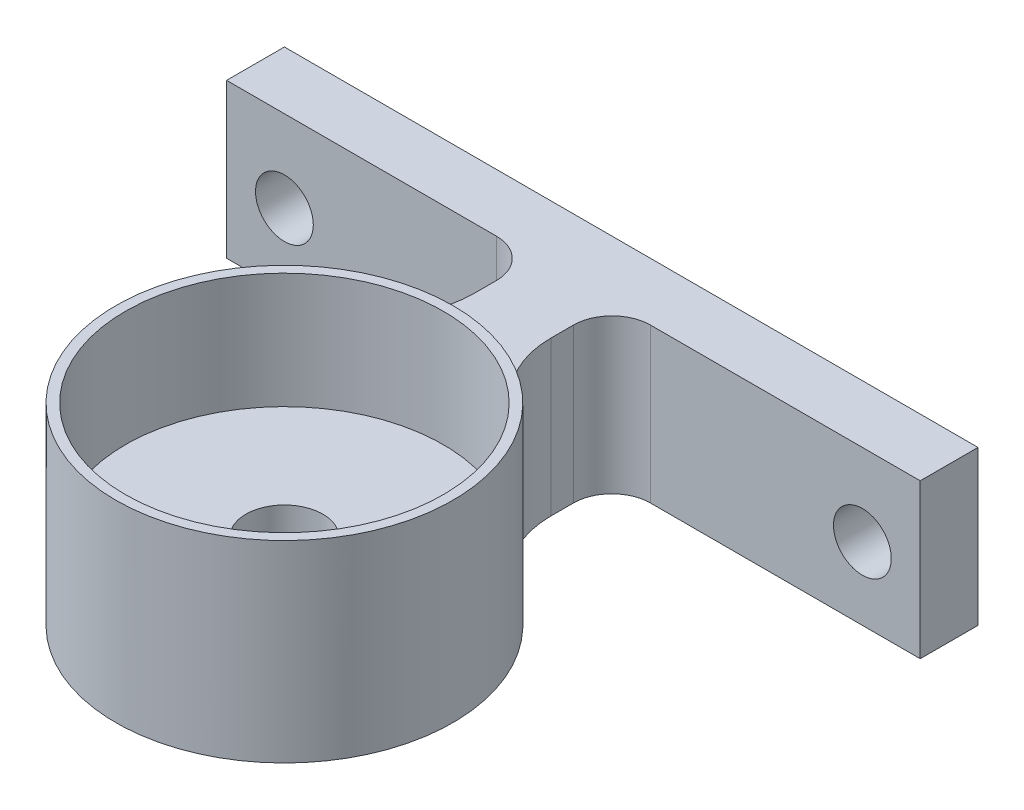
from build123d import *

# Parameters (mm, degrees)
SKETCH_1_R          = 8.75
SKETCH_1_R_2        = 8.25
EXTRUDE_2_DEPTH     = 10
SKETCH_2_R          = 8.25
SKETCH_2_R_2        = 2
EXTRUDE_3_DEPTH     = 4
EXTRUDE_4_DEPTH     = 8
SKETCH_5_W          = 3
SKETCH_5_H          = 8
EXTRUDE_5_DEPTH     = 3
SKETCH_6_W          = 3
SKETCH_6_H          = 8
EXTRUDE_6_DEPTH     = 3
SKETCH_7_R          = 1.5
CUT_EXTRUDE_1_DEPTH = 3
FILLET_1_R          = 5
FILLET_3_R          = 2
SKETCH_8_R          = 8.75
SKETCH_8_R_2        = 8.25
EXTRUDE_7_DEPTH     = 8
SKETCH_9_R          = 8.25
SKETCH_9_R_2        = 6
EXTRUDE_8_DEPTH     = 2
EXTRUDE_9_DEPTH     = 8
SKETCH_11_R         = 1.5
CUT_EXTRUDE_2_DEPTH = 8
CUT_EXTRUDE_3_DEPTH = 8
CUT_EXTRUDE_4_DEPTH = 8
SKETCH_14_R         = 8.75
SKETCH_14_R_2       = 8.25
EXTRUDE_10_DEPTH    = 8
EXTRUDE_11_DEPTH    = 8
SKETCH_16_R         = 1.5
CUT_EXTRUDE_5_DEPTH = 8
CUT_EXTRUDE_6_DEPTH = 10


with BuildPart() as part:
    # 草图1 → 凸台-拉伸2 (new body)
    with BuildSketch(Plane(origin=(0, 0, 0), x_dir=(1, 0, 0), z_dir=(0, 1, 0))):
        Circle(SKETCH_1_R)
        Circle(SKETCH_1_R_2, mode=Mode.SUBTRACT)
    extrude(amount=EXTRUDE_2_DEPTH)

    # 草图2 → 凸台-拉伸3 (add)
    with BuildSketch(Plane(origin=(0, 0, 0), x_dir=(1, 0, 0), z_dir=(0, 1, 0))):
        Circle(SKETCH_2_R)
        Circle(SKETCH_2_R_2, mode=Mode.SUBTRACT)
    extrude(amount=EXTRUDE_3_DEPTH)

    # 草图3 → 凸台-拉伸4 (add)
    with BuildSketch(Plane(origin=(0, 0, 0), x_dir=(1, 0, 0), z_dir=(0, 1, 0))):
        Polygon((-2, 8.518362519), (2, 8.518362519), (2, 15), (15, 15), (15, 18), (2, 18), (-2, 18), (-15, 18), (-15, 15), (-2, 15), align=None)
    extrude(amount=EXTRUDE_4_DEPTH)

    # 草图5 → 凸台-拉伸5 (add)
    with BuildSketch(Plane(origin=(15, 0, 0), x_dir=(0, 0, -1), z_dir=(1, 0, 0))):
        with Locations((16.5, 4)):
            Rectangle(SKETCH_5_W, SKETCH_5_H)
    extrude(amount=EXTRUDE_5_DEPTH)

    # 草图6 → 凸台-拉伸6 (add)
    with BuildSketch(Plane.ZY.offset(15)):
        with Locations((-16.5, 4)):
            Rectangle(SKETCH_6_W, SKETCH_6_H)
    extrude(amount=EXTRUDE_6_DEPTH)

    # 草图7 → 切除-拉伸1 (cut)
    with BuildSketch(Plane(origin=(0, 0, -18), x_dir=(-1, 0, 0), z_dir=(0, 0, -1))):
        with Locations((-15, 3.754021035)):
            Circle(SKETCH_7_R)
    cut_extrude_1 = extrude(amount=-CUT_EXTRUDE_1_DEPTH, mode=Mode.SUBTRACT)

    # 镜向1: 切除-拉伸1 across plane
    add(cut_extrude_1.mirror(Plane(origin=(0, 0, 0), x_dir=(0, 0, 1), z_dir=(1, 0, 0))), mode=Mode.SUBTRACT)

    # 圆角1
    fillet_1_edges = [part.edges().sort_by_distance(p)[0] for p in [
        (-2, 4, -8.518362519),
        (2, 4, -8.518362519),
    ]]
    fillet(fillet_1_edges, radius=FILLET_1_R)

    # 圆角3
    fillet_3_edges = [part.edges().sort_by_distance(p)[0] for p in [
        (-2, 4, -15),
        (2, 4, -15),
    ]]
    fillet(fillet_3_edges, radius=FILLET_3_R)


with BuildPart() as body_2:
    # 草图8 → 凸台-拉伸7 (new body)
    with BuildSketch(Plane(origin=(0, 0, 0), x_dir=(1, 0, 0), z_dir=(0, 1, 0))):
        with Locations((27.184954533, 0)):
            Circle(SKETCH_8_R)
        with Locations((27.184954533, 0)):
            Circle(SKETCH_8_R_2, mode=Mode.SUBTRACT)
    extrude(amount=EXTRUDE_7_DEPTH)

    # 草图9 → 凸台-拉伸8 (add)
    with BuildSketch(Plane.XZ):
        with Locations((27.184954533, 0)):
            Circle(SKETCH_9_R)
        with Locations((27.184954533, 0)):
            Circle(SKETCH_9_R_2, mode=Mode.SUBTRACT)
    extrude(amount=-EXTRUDE_8_DEPTH)

    # 草图10 → 凸台-拉伸9 (add)
    with BuildSketch(Plane(origin=(0, 0, 0), x_dir=(1, 0, 0), z_dir=(0, 1, 0))):
        Polygon((27.184954533, -18), (45.184954533, -18), (45.184954533, -14.663867829), (29.184954533, -14.663867829), (29.184954533, -8.518362519), (25.184954533, -8.518362519), (25.184954533, -14.663867829), (9.184954533, -14.663867829), (9.184954533, -18), align=None)
    extrude(amount=EXTRUDE_9_DEPTH)

    # 草图11 → 切除-拉伸2 (cut)
    with BuildSketch(Plane.XY.offset(18)):
        with Locations((12.184954533, 4)):
            Circle(SKETCH_11_R)
        with Locations((42.184954533, 4)):
            Circle(SKETCH_11_R)
    extrude(amount=-CUT_EXTRUDE_2_DEPTH, mode=Mode.SUBTRACT)

    # 草图12 → 切除-拉伸3 (cut)
    with BuildSketch(Plane.XY.offset(18)):
        with BuildLine():
            Line((10.684954533, 4), (10.684954533, 5))
            ThreePointArc((10.684954533, 5), (12.184954533, 6.5), (13.684954533, 5))
            Line((13.684954533, 5), (13.684954533, 4))
            Line((13.684954533, 4), (13.684954533, 3))
            ThreePointArc((13.684954533, 3), (12.184954533, 1.5), (10.684954533, 3))
            Line((10.684954533, 3), (10.684954533, 4))
        make_face()
    extrude(amount=-CUT_EXTRUDE_3_DEPTH, mode=Mode.SUBTRACT)

    # 草图13 → 切除-拉伸4 (cut)
    with BuildSketch(Plane.XY.offset(18)):
        with BuildLine():
            Line((40.684954533, 4), (40.684954533, 5))
            ThreePointArc((40.684954533, 5), (42.184954533, 6.5), (43.684954533, 5))
            Line((43.684954533, 5), (43.684954533, 4))
            Line((43.684954533, 4), (43.684954533, 3))
            ThreePointArc((43.684954533, 3), (42.184954533, 1.5), (40.684954533, 3))
            Line((40.684954533, 3), (40.684954533, 4))
        make_face()
    extrude(amount=-CUT_EXTRUDE_4_DEPTH, mode=Mode.SUBTRACT)


with BuildPart() as body_3:
    # 草图14 → 凸台-拉伸10 (new body)
    with BuildSketch(Plane(origin=(0, 0, 0), x_dir=(1, 0, 0), z_dir=(0, 1, 0))):
        with Locations((-35.091635024, 0)):
            Circle(SKETCH_14_R)
        with Locations((-35.091635024, 0)):
            Circle(SKETCH_14_R_2, mode=Mode.SUBTRACT)
    extrude(amount=EXTRUDE_10_DEPTH)

    # 草图15 → 凸台-拉伸11 (add)
    with BuildSketch(Plane(origin=(0, 0, 0), x_dir=(1, 0, 0), z_dir=(0, 1, 0))):
        Polygon((-37.091635024, -15), (-37.091635024, -8.518362519), (-33.091635024, -8.518362519), (-33.091635024, -15), (-17.091635024, -15), (-17.091635024, -18), (-53.091635024, -18), (-53.091635024, -15), align=None)
    extrude(amount=EXTRUDE_11_DEPTH)

    # 草图16 → 切除-拉伸5 (cut)
    with BuildSketch(Plane.XY.offset(18)):
        with Locations((-50.091635024, 4)):
            Circle(SKETCH_16_R)
        with Locations((-20.091635024, 4)):
            Circle(SKETCH_16_R)
    extrude(amount=-CUT_EXTRUDE_5_DEPTH, mode=Mode.SUBTRACT)


with BuildPart() as cut_extrude_6_tool:
    # 草图17 → 切除-拉伸6 (new body)
    with BuildSketch(Plane(origin=(0, 0, 0), x_dir=(1, 0, 0), z_dir=(0, 1, 0))):
        Polygon((-33.937696103, 15.405684546), (-2.722219819, -15.809791737), (14.647012306, -5.078130135), (14.647012306, 8.915639327), (41.967984005, 12.760711076), (60.531615551, -22.761160297), (-4.034255232, -33.891518563), (-68.183747723, -30.767123944), (-78.804576394, -10.443960936), (-56.287548242, 12.073067216), align=None)
    extrude(amount=CUT_EXTRUDE_6_DEPTH)


with BuildPart() as body_2_1:
    add(body_2.part)

    # 切除-拉伸6: cut by cut_extrude_6_tool
    add(cut_extrude_6_tool.part, mode=Mode.SUBTRACT)


with BuildPart() as body_3_1:
    add(body_3.part)

    # 切除-拉伸6: cut by cut_extrude_6_tool
    add(cut_extrude_6_tool.part, mode=Mode.SUBTRACT)


solid = part.part
